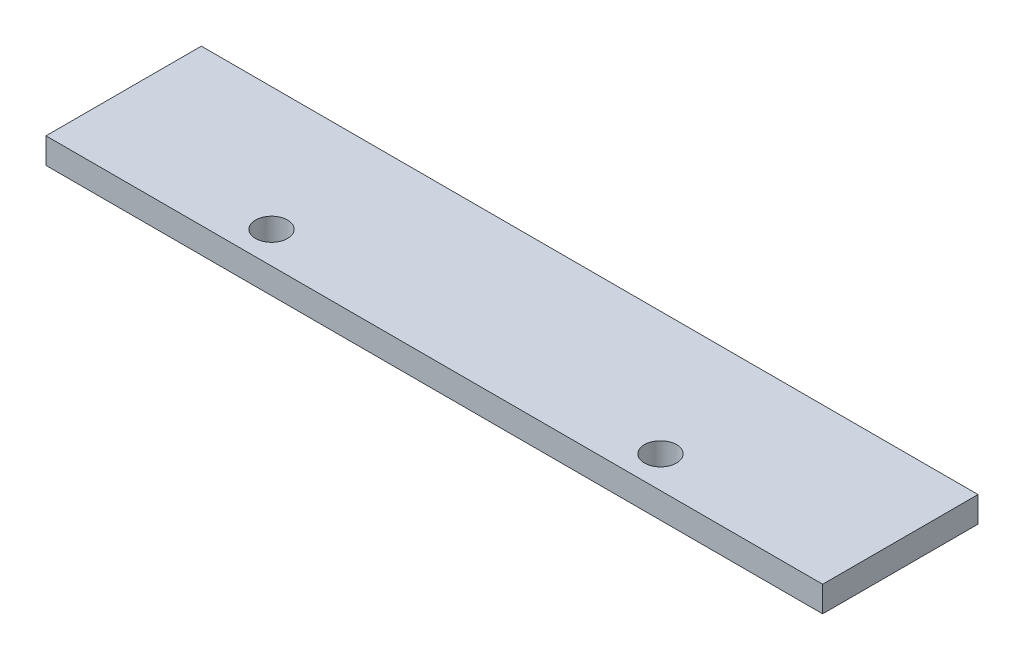
from build123d import *

# Parameters (mm, degrees)
SKETCH1_W           = 51.1
SKETCH1_H           = 10.22
BOSS_EXTRUDE1_DEPTH = 0.845
SKETCH2_R           = 1.054294776
CUT_EXTRUDE1_DEPTH  = 2.69


with BuildPart() as part:
    # Sketch1 → Boss-Extrude1 (new body, symmetric)
    with BuildSketch(Plane(origin=(0, 0, 0), x_dir=(1, 0, 0), z_dir=(0, 1, 0))):
        Rectangle(SKETCH1_W, SKETCH1_H)
    extrude(amount=BOSS_EXTRUDE1_DEPTH, both=True)

    # Sketch2 → Cut-Extrude1 (cut, through all)
    with BuildSketch(Plane(origin=(0, 0.845, 0), x_dir=(1, 0, 0), z_dir=(0, 1, 0))):
        with Locations((-12.806496192, -3.015690418)):
            Circle(SKETCH2_R)
        with Locations((12.785993514, -3.015690418)):
            Circle(SKETCH2_R)
    extrude(amount=-CUT_EXTRUDE1_DEPTH, mode=Mode.SUBTRACT)


solid = part.part
